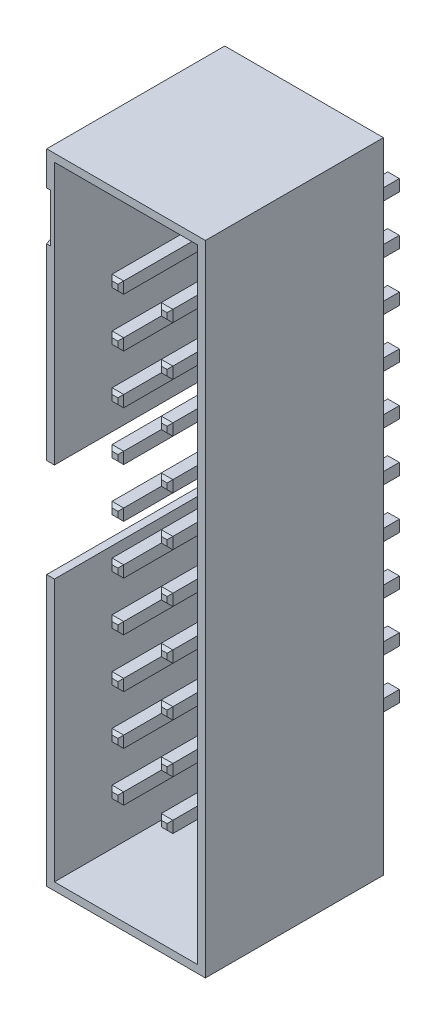
from build123d import *

# Parameters (mm, degrees)
ESQUISSE1_W             = 8.2
ESQUISSE1_H             = 33
BOSS_EXTRU_1_DEPTH      = 9.2
ESQUISSE2_W             = 7.4
ESQUISSE2_H             = 32.2
ENL_V_MAT_EXTRU_1_DEPTH = 8
ESQUISSE3_W             = 0.6
ESQUISSE3_H             = 0.6
BOSS_EXTRU_2_DEPTH      = 3.5
BOSS_EXTRU_2_DEPTH_BACK = 8.5
CHANFREIN1_SIZE         = 0.15
ESQUISSE4_W             = 0.4
ESQUISSE4_H             = 5.1
ENL_V_MAT_EXTRU_2_DEPTH = 8
ENL_V_MAT_EXTRU_3_DEPTH = 0.2


with BuildPart() as part:
    # Esquisse1 → Boss.-Extru.1 (new body)
    with BuildSketch(Plane.XY):
        with Locations((4.1, 16.5)):
            Rectangle(ESQUISSE1_W, ESQUISSE1_H)
    extrude(amount=BOSS_EXTRU_1_DEPTH)

    # Esquisse2 → Enlèv. mat.-Extru.1 (cut)
    with BuildSketch(Plane.XY.offset(9.2)):
        with Locations((4.1, 16.5)):
            Rectangle(ESQUISSE2_W, ESQUISSE2_H)
    extrude(amount=-ENL_V_MAT_EXTRU_1_DEPTH, mode=Mode.SUBTRACT)

    # Esquisse3 → Boss.-Extru.2 (add, two sides)
    with BuildSketch(Plane(origin=(0, 0, 0), x_dir=(-1, 0, 0), z_dir=(0, 0, -1))) as boss_extru_2_sk:
        with Locations((-5.37, 27.93)):
            Rectangle(ESQUISSE3_W, ESQUISSE3_H)
        with Locations((-2.83, 27.93)):
            Rectangle(ESQUISSE3_W, ESQUISSE3_H)
        with Locations((-5.37, 25.39)):
            Rectangle(ESQUISSE3_W, ESQUISSE3_H)
        with Locations((-2.83, 25.39)):
            Rectangle(ESQUISSE3_W, ESQUISSE3_H)
        with Locations((-5.37, 22.85)):
            Rectangle(ESQUISSE3_W, ESQUISSE3_H)
        with Locations((-2.83, 22.85)):
            Rectangle(ESQUISSE3_W, ESQUISSE3_H)
        with Locations((-5.37, 20.31)):
            Rectangle(ESQUISSE3_W, ESQUISSE3_H)
        with Locations((-2.83, 20.31)):
            Rectangle(ESQUISSE3_W, ESQUISSE3_H)
        with Locations((-5.37, 17.77)):
            Rectangle(ESQUISSE3_W, ESQUISSE3_H)
        with Locations((-2.83, 17.77)):
            Rectangle(ESQUISSE3_W, ESQUISSE3_H)
        with Locations((-5.37, 15.23)):
            Rectangle(ESQUISSE3_W, ESQUISSE3_H)
        with Locations((-2.83, 15.23)):
            Rectangle(ESQUISSE3_W, ESQUISSE3_H)
        with Locations((-5.37, 12.69)):
            Rectangle(ESQUISSE3_W, ESQUISSE3_H)
        with Locations((-2.83, 12.69)):
            Rectangle(ESQUISSE3_W, ESQUISSE3_H)
        with Locations((-5.37, 10.15)):
            Rectangle(ESQUISSE3_W, ESQUISSE3_H)
        with Locations((-2.83, 10.15)):
            Rectangle(ESQUISSE3_W, ESQUISSE3_H)
        with Locations((-5.37, 7.61)):
            Rectangle(ESQUISSE3_W, ESQUISSE3_H)
        with Locations((-2.83, 7.61)):
            Rectangle(ESQUISSE3_W, ESQUISSE3_H)
        with Locations((-5.37, 5.07)):
            Rectangle(ESQUISSE3_W, ESQUISSE3_H)
        with Locations((-2.83, 5.07)):
            Rectangle(ESQUISSE3_W, ESQUISSE3_H)
    extrude(amount=BOSS_EXTRU_2_DEPTH)
    extrude(boss_extru_2_sk.sketch, amount=-BOSS_EXTRU_2_DEPTH_BACK)

    # Chanfrein1
    chanfrein1_edges = [part.edges().sort_by_distance(p)[0] for p in [
        (5.07, 22.85, 8.5),
        (5.37, 22.55, 8.5),
        (5.67, 22.85, 8.5),
        (5.37, 23.15, 8.5),
        (5.07, 22.85, -3.5),
        (5.37, 23.15, -3.5),
        (5.67, 22.85, -3.5),
        (5.37, 22.55, -3.5),
        (2.53, 22.85, 8.5),
        (2.83, 22.55, 8.5),
        (3.13, 22.85, 8.5),
        (2.83, 23.15, 8.5),
        (2.53, 22.85, -3.5),
        (2.83, 23.15, -3.5),
        (3.13, 22.85, -3.5),
        (2.83, 22.55, -3.5),
        (5.07, 20.31, 8.5),
        (5.37, 20.01, 8.5),
        (5.67, 20.31, 8.5),
        (5.37, 20.61, 8.5),
        (5.07, 20.31, -3.5),
        (5.37, 20.61, -3.5),
        (5.67, 20.31, -3.5),
        (5.37, 20.01, -3.5),
        (2.53, 20.31, 8.5),
        (2.83, 20.01, 8.5),
        (3.13, 20.31, 8.5),
        (2.83, 20.61, 8.5),
        (2.53, 20.31, -3.5),
        (2.83, 20.61, -3.5),
        (3.13, 20.31, -3.5),
        (2.83, 20.01, -3.5),
        (5.07, 17.77, 8.5),
        (5.37, 17.47, 8.5),
        (5.67, 17.77, 8.5),
        (5.37, 18.07, 8.5),
        (5.07, 17.77, -3.5),
        (5.37, 18.07, -3.5),
        (5.67, 17.77, -3.5),
        (5.37, 17.47, -3.5),
        (2.53, 17.77, 8.5),
        (2.83, 17.47, 8.5),
        (3.13, 17.77, 8.5),
        (2.83, 18.07, 8.5),
        (2.53, 17.77, -3.5),
        (2.83, 18.07, -3.5),
        (3.13, 17.77, -3.5),
        (2.83, 17.47, -3.5),
        (5.07, 15.23, 8.5),
        (5.37, 14.93, 8.5),
        (5.67, 15.23, 8.5),
        (5.37, 15.53, 8.5),
        (5.07, 15.23, -3.5),
        (5.37, 15.53, -3.5),
        (5.67, 15.23, -3.5),
        (5.37, 14.93, -3.5),
        (2.53, 15.23, 8.5),
        (2.83, 14.93, 8.5),
        (3.13, 15.23, 8.5),
        (2.83, 15.53, 8.5),
        (2.53, 15.23, -3.5),
        (2.83, 15.53, -3.5),
        (3.13, 15.23, -3.5),
        (2.83, 14.93, -3.5),
        (5.07, 12.69, 8.5),
        (5.37, 12.39, 8.5),
        (5.67, 12.69, 8.5),
        (5.37, 12.99, 8.5),
        (5.07, 12.69, -3.5),
        (5.37, 12.99, -3.5),
        (5.67, 12.69, -3.5),
        (5.37, 12.39, -3.5),
        (2.53, 12.69, 8.5),
        (2.83, 12.39, 8.5),
        (3.13, 12.69, 8.5),
        (2.83, 12.99, 8.5),
        (2.53, 12.69, -3.5),
        (2.83, 12.99, -3.5),
        (3.13, 12.69, -3.5),
        (2.83, 12.39, -3.5),
        (5.07, 27.93, 8.5),
        (5.07, 10.15, 8.5),
        (5.37, 9.85, 8.5),
        (5.67, 10.15, 8.5),
        (5.37, 10.45, 8.5),
        (5.37, 27.63, 8.5),
        (5.07, 10.15, -3.5),
        (5.37, 10.45, -3.5),
        (5.67, 10.15, -3.5),
        (5.37, 9.85, -3.5),
        (5.67, 27.93, 8.5),
        (5.37, 28.23, 8.5),
        (2.53, 10.15, 8.5),
        (2.83, 9.85, 8.5),
        (3.13, 10.15, 8.5),
        (2.83, 10.45, 8.5),
        (2.53, 10.15, -3.5),
        (2.83, 10.45, -3.5),
        (3.13, 10.15, -3.5),
        (2.83, 9.85, -3.5),
        (5.07, 27.93, -3.5),
        (5.37, 28.23, -3.5),
        (5.67, 27.93, -3.5),
        (5.37, 27.63, -3.5),
        (5.07, 7.61, 8.5),
        (5.37, 7.31, 8.5),
        (5.67, 7.61, 8.5),
        (5.37, 7.91, 8.5),
        (5.07, 7.61, -3.5),
        (5.37, 7.91, -3.5),
        (5.67, 7.61, -3.5),
        (5.37, 7.31, -3.5),
        (2.53, 7.61, 8.5),
        (2.83, 7.31, 8.5),
        (3.13, 7.61, 8.5),
        (2.83, 7.91, 8.5),
        (2.53, 7.61, -3.5),
        (2.83, 7.91, -3.5),
        (3.13, 7.61, -3.5),
        (2.83, 7.31, -3.5),
        (5.07, 5.07, 8.5),
        (5.37, 4.77, 8.5),
        (5.67, 5.07, 8.5),
        (5.37, 5.37, 8.5),
        (5.07, 5.07, -3.5),
        (5.37, 5.37, -3.5),
        (5.67, 5.07, -3.5),
        (5.37, 4.77, -3.5),
        (2.53, 5.07, 8.5),
        (2.83, 4.77, 8.5),
        (3.13, 5.07, 8.5),
        (2.83, 5.37, 8.5),
        (2.53, 5.07, -3.5),
        (2.83, 5.37, -3.5),
        (3.13, 5.07, -3.5),
        (2.83, 4.77, -3.5),
        (2.53, 27.93, 8.5),
        (2.83, 27.63, 8.5),
        (3.13, 27.93, 8.5),
        (2.83, 28.23, 8.5),
        (2.53, 27.93, -3.5),
        (2.83, 28.23, -3.5),
        (3.13, 27.93, -3.5),
        (2.83, 27.63, -3.5),
        (5.07, 25.39, 8.5),
        (5.37, 25.09, 8.5),
        (5.67, 25.39, 8.5),
        (5.37, 25.69, 8.5),
        (5.07, 25.39, -3.5),
        (5.37, 25.69, -3.5),
        (5.67, 25.39, -3.5),
        (5.37, 25.09, -3.5),
        (2.53, 25.39, 8.5),
        (2.83, 25.09, 8.5),
        (3.13, 25.39, 8.5),
        (2.83, 25.69, 8.5),
        (2.53, 25.39, -3.5),
        (2.83, 25.69, -3.5),
        (3.13, 25.39, -3.5),
        (2.83, 25.09, -3.5),
    ]]
    chamfer(chanfrein1_edges, length=CHANFREIN1_SIZE)

    # Esquisse4 → Enlèv. mat.-Extru.2 (cut)
    with BuildSketch(Plane.XY.offset(9.2)):
        with Locations((0.2, 16.5)):
            Rectangle(ESQUISSE4_W, ESQUISSE4_H)
    extrude(amount=-ENL_V_MAT_EXTRU_2_DEPTH, mode=Mode.SUBTRACT)

    # Esquisse5 → Enlèv. mat.-Extru.3 (cut)
    with BuildSketch(Plane.ZY):
        Polygon((9.2, 31.25), (9.2, 28.75), (7.034936491, 30), align=None)
    extrude(amount=-ENL_V_MAT_EXTRU_3_DEPTH, mode=Mode.SUBTRACT)


solid = part.part
